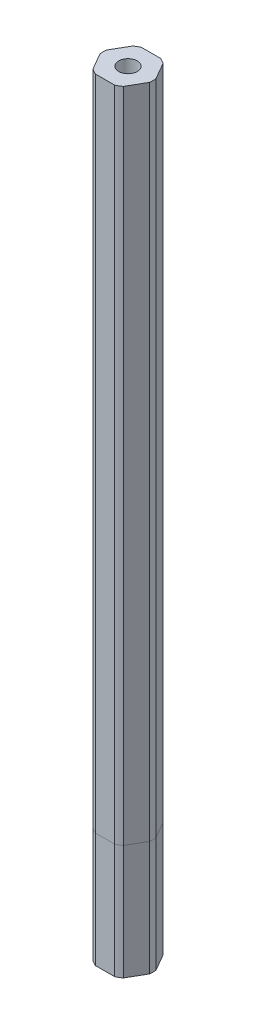
from build123d import *

# Parameters (mm, degrees)
SKETCH1_R           = 4.0005
BOSS_EXTRUDE1_DEPTH = 31.623
SKETCH2_R           = 2.5527
BOSS_EXTRUDE2_DEPTH = 181.102


with BuildPart() as part:
    # Sketch1 → Boss-Extrude1 (new body)
    with BuildSketch(Plane(origin=(0, 0, 0), x_dir=(1, 0, 0), z_dir=(0, 1, 0))):
        with BuildLine():
            Line((6.817769051, 0.89127761), (4.180753577, 5.45872239))
            ThreePointArc((4.180753577, 5.45872239), (3.43789, 5.954600151), (2.637015474, 6.35))
            Line((2.637015474, 6.35), (-2.637015474, 6.35))
            ThreePointArc((-2.637015474, 6.35), (-3.43789, 5.954600151), (-4.180753577, 5.45872239))
            Line((-4.180753577, 5.45872239), (-6.817769051, 0.89127761))
            ThreePointArc((-6.817769051, 0.89127761), (-6.87578, 0), (-6.817769051, -0.89127761))
            Line((-6.817769051, -0.89127761), (-4.180753577, -5.45872239))
            ThreePointArc((-4.180753577, -5.45872239), (-3.43789, -5.954600151), (-2.637015474, -6.35))
            Line((-2.637015474, -6.35), (2.637015474, -6.35))
            ThreePointArc((2.637015474, -6.35), (3.43789, -5.954600151), (4.180753577, -5.45872239))
            Line((4.180753577, -5.45872239), (6.817769051, -0.89127761))
            ThreePointArc((6.817769051, -0.89127761), (6.87578, 0), (6.817769051, 0.89127761))
        make_face()
        Circle(SKETCH1_R, mode=Mode.SUBTRACT)
    extrude(amount=BOSS_EXTRUDE1_DEPTH)


with BuildPart() as body_2:
    # Sketch2 → Boss-Extrude2 (new body)
    with BuildSketch(Plane(origin=(0, 31.623, 0), x_dir=(1, 0, 0), z_dir=(0, 1, 0))):
        with BuildLine():
            Line((2.637015474, 6.35), (-2.637015474, 6.35))
            ThreePointArc((-2.637015474, 6.35), (-3.43789, 5.954600151), (-4.180753577, 5.45872239))
            Line((-4.180753577, 5.45872239), (-6.817769051, 0.89127761))
            ThreePointArc((-6.817769051, 0.89127761), (-6.87578, 0), (-6.817769051, -0.89127761))
            Line((-6.817769051, -0.89127761), (-4.180753577, -5.45872239))
            ThreePointArc((-4.180753577, -5.45872239), (-3.43789, -5.954600151), (-2.637015474, -6.35))
            Line((-2.637015474, -6.35), (2.637015474, -6.35))
            ThreePointArc((2.637015474, -6.35), (3.43789, -5.954600151), (4.180753577, -5.45872239))
            Line((4.180753577, -5.45872239), (6.817769051, -0.89127761))
            ThreePointArc((6.817769051, -0.89127761), (6.87578, 0), (6.817769051, 0.89127761))
            Line((6.817769051, 0.89127761), (4.180753577, 5.45872239))
            ThreePointArc((4.180753577, 5.45872239), (3.43789, 5.954600151), (2.637015474, 6.35))
        make_face()
        Circle(SKETCH2_R, mode=Mode.SUBTRACT)
    extrude(amount=BOSS_EXTRUDE2_DEPTH)


solid = Compound([part.part, body_2.part])
